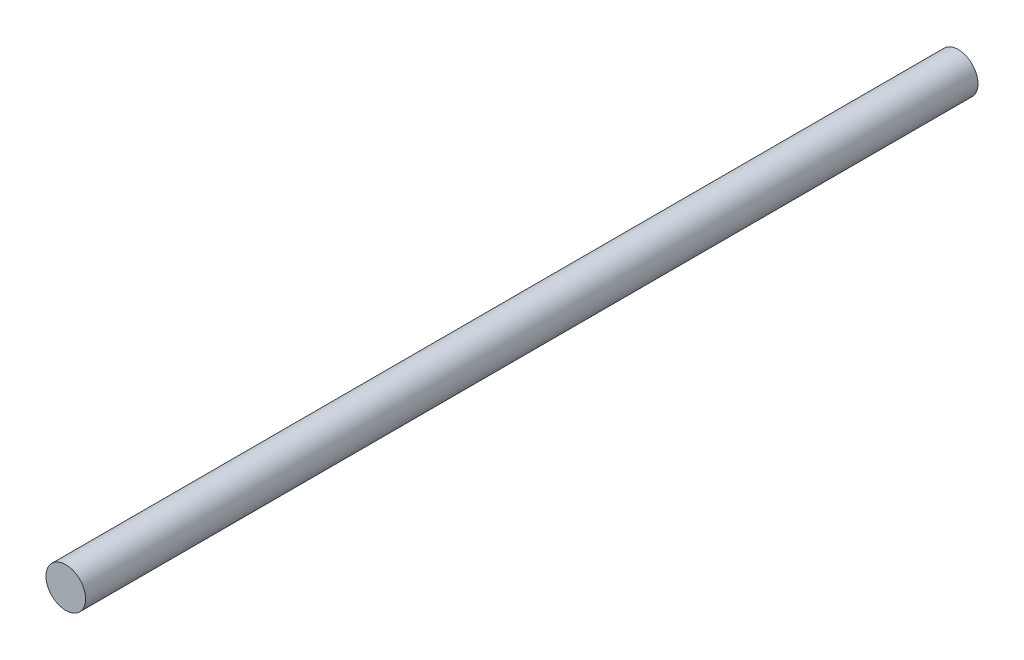
from build123d import *

# Parameters (mm, degrees)
SKETCH1_R           = 3.175
BOSS_EXTRUDE1_DEPTH = 142.875


with BuildPart() as part:
    # Sketch1 → Boss-Extrude1 (new body)
    with BuildSketch(Plane.XY):
        Circle(SKETCH1_R)
    extrude(amount=BOSS_EXTRUDE1_DEPTH)


solid = part.part
